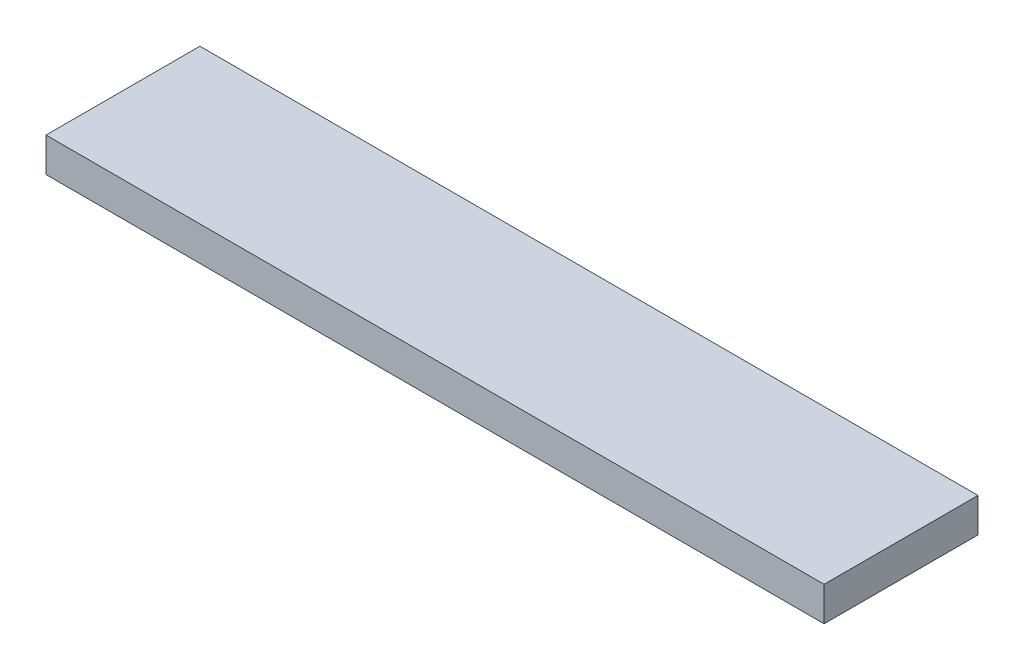
from build123d import *

# Parameters (mm, degrees)
SKETCH1_W           = 182
SKETCH1_H           = 36
BOSS_EXTRUDE1_DEPTH = 8


with BuildPart() as part:
    # Sketch1 → Boss-Extrude1 (new body)
    with BuildSketch(Plane(origin=(0, 0, 0), x_dir=(1, 0, 0), z_dir=(0, 1, 0))):
        with Locations((91, 18)):
            Rectangle(SKETCH1_W, SKETCH1_H)
    extrude(amount=BOSS_EXTRUDE1_DEPTH)


solid = part.part
